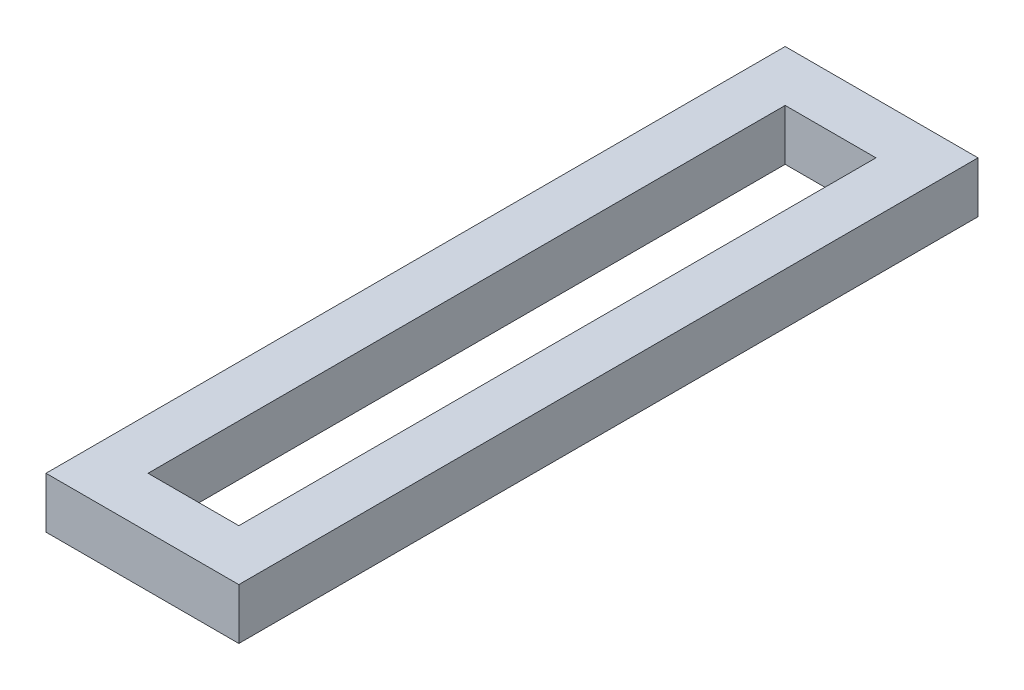
from build123d import *

# Parameters (mm, degrees)
SKETCH1_W           = 60
SKETCH1_H           = 230
SKETCH1_W_2         = 28.25
SKETCH1_H_2         = 198.25
BOSS_EXTRUDE1_DEPTH = 15.875


with BuildPart() as part:
    # Sketch1 → Boss-Extrude1 (new body)
    with BuildSketch(Plane(origin=(0, 0, 0), x_dir=(1, 0, 0), z_dir=(0, 1, 0))):
        Rectangle(SKETCH1_W, SKETCH1_H)
        Rectangle(SKETCH1_W_2, SKETCH1_H_2, mode=Mode.SUBTRACT)
    extrude(amount=BOSS_EXTRUDE1_DEPTH)


solid = part.part
